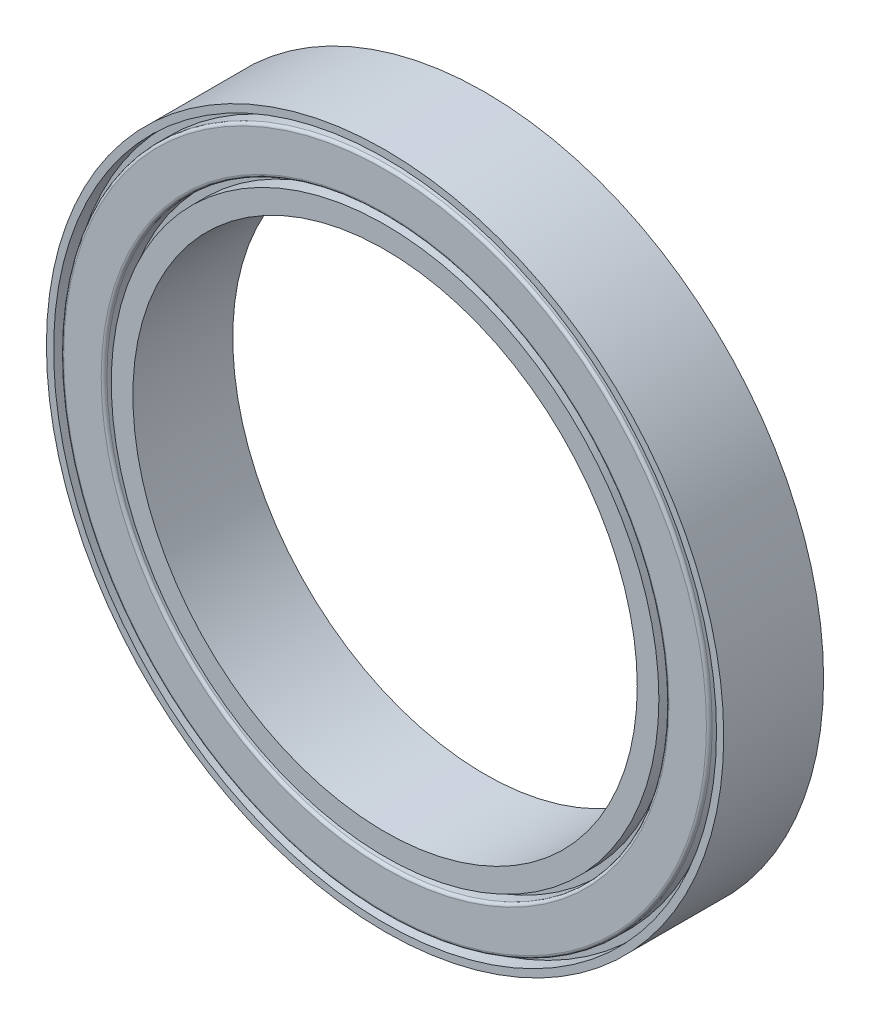
from build123d import *

# Parameters (mm, degrees)
SKETCH1_R           = 23.5
SKETCH1_R_2         = 17.5
BOSS_EXTRUDE1_DEPTH = 6.93
SKETCH2_R           = 23
SKETCH2_R_2         = 22.5
CUT_EXTRUDE1_DEPTH  = 1
SKETCH3_R           = 19.5
SKETCH3_R_2         = 19
CUT_EXTRUDE2_DEPTH  = 1
FILLET1_R           = 0.2


with BuildPart() as part:
    # Sketch1 → Boss-Extrude1 (new body)
    with BuildSketch(Plane.XY):
        Circle(SKETCH1_R)
        Circle(SKETCH1_R_2, mode=Mode.SUBTRACT)
    extrude(amount=BOSS_EXTRUDE1_DEPTH)

    # Sketch2 → Cut-Extrude1 (cut)
    with BuildSketch(Plane.XY.offset(6.93)):
        Circle(SKETCH2_R)
        Circle(SKETCH2_R_2, mode=Mode.SUBTRACT)
    cut_extrude1 = extrude(amount=-CUT_EXTRUDE1_DEPTH, mode=Mode.SUBTRACT)

    # Sketch3 → Cut-Extrude2 (cut)
    with BuildSketch(Plane.XY.offset(6.93)):
        Circle(SKETCH3_R)
        Circle(SKETCH3_R_2, mode=Mode.SUBTRACT)
    cut_extrude2 = extrude(amount=-CUT_EXTRUDE2_DEPTH, mode=Mode.SUBTRACT)

    # Mirror1: Cut-Extrude1, Cut-Extrude2 across plane
    add(cut_extrude1.mirror(Plane.XY.offset(3.465)), mode=Mode.SUBTRACT)
    add(cut_extrude2.mirror(Plane.XY.offset(3.465)), mode=Mode.SUBTRACT)

    # Fillet1
    fillet1_edges = [part.edges().sort_by_distance(p)[0] for p in [
        (-22.5, 0, 6.93),
        (-19.5, 0, 6.93),
        (-22.5, 0, 0),
        (-19.5, 0, 0),
    ]]
    fillet(fillet1_edges, radius=FILLET1_R)


solid = part.part
